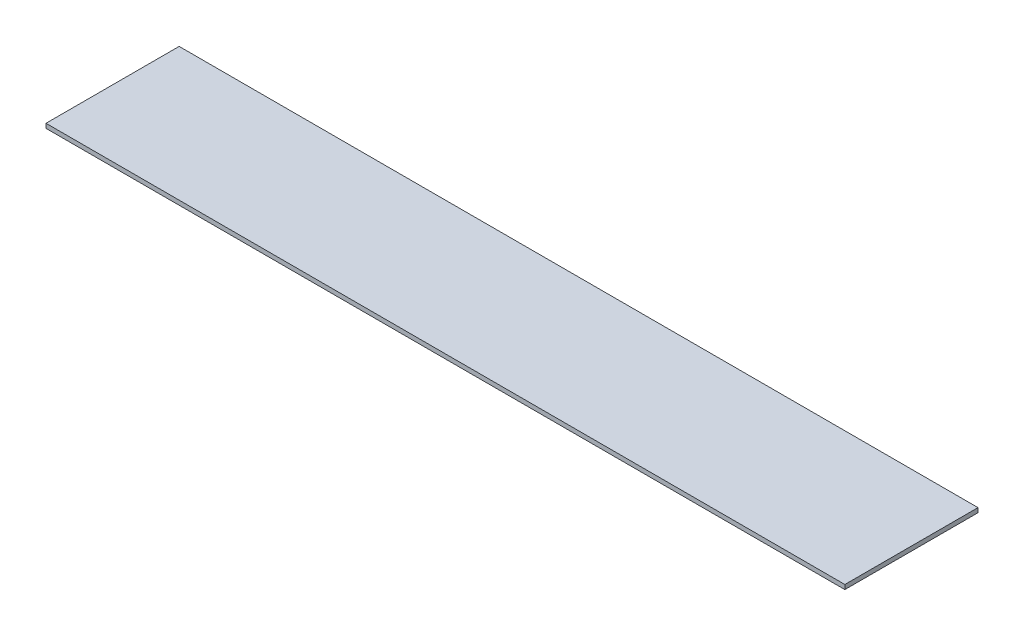
from build123d import *

# Parameters (mm, degrees)
SKETCH1_W           = 900
SKETCH1_H           = 150
BOSS_EXTRUDE1_DEPTH = 5


with BuildPart() as part:
    # Sketch1 → Boss-Extrude1 (new body)
    with BuildSketch(Plane(origin=(0, 0, 0), x_dir=(1, 0, 0), z_dir=(0, 1, 0))):
        Rectangle(SKETCH1_W, SKETCH1_H)
    extrude(amount=BOSS_EXTRUDE1_DEPTH)


solid = part.part
